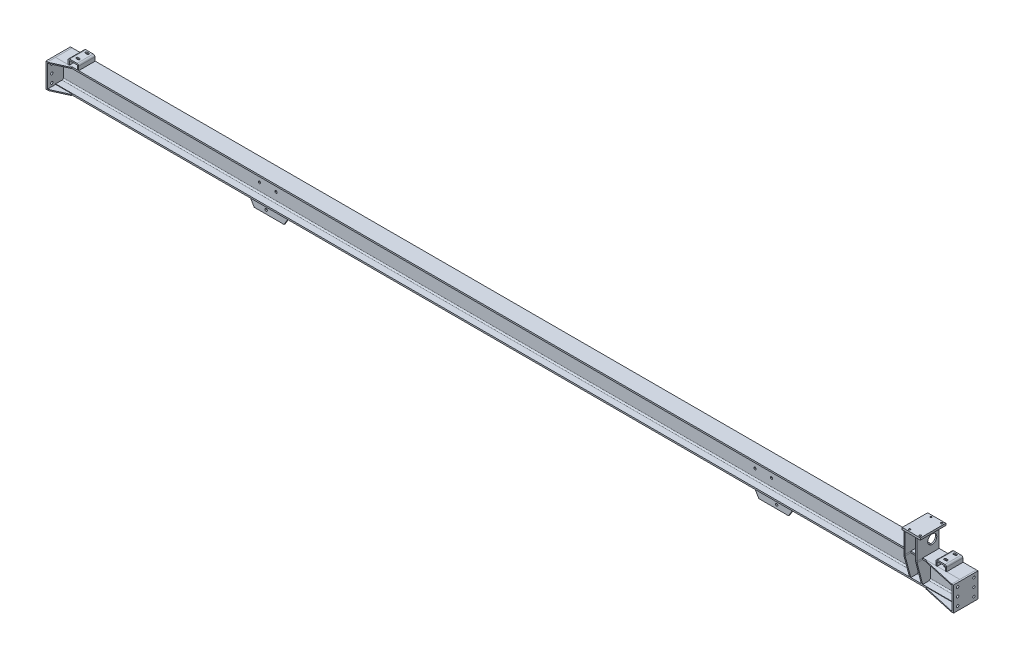
from build123d import *

# Parameters (mm, degrees)
H_HM150_100_3_DEPTH      = 5475
SKETCH_18_W              = 148
SKETCH_18_H              = 148
EXTRUDE_1_DEPTH          = 10
SKETCH_19_W              = 148
SKETCH_19_H              = 148
EXTRUDE_2_DEPTH          = 10
EXTRUDE_3_DEPTH          = 6
EXTRUDE_4_DEPTH          = 6
EXTRUDE_5_DEPTH          = 6
EXTRUDE_6_DEPTH          = 6
SKETCH_24_R              = 7
CUT_EXTRUDE_1_DEPTH      = 10
SKETCH_25_R              = 7
CUT_EXTRUDE_2_DEPTH      = 10
SKETCH_26_R              = 7
CUT_EXTRUDE_3_DEPTH      = 7593.985158926
CUT_EXTRUDE_3_DEPTH_BACK = 6
SKETCH_27_W              = 110
SKETCH_27_H              = 154
SKETCH_27_R              = 5.5
EXTRUDE_7_DEPTH          = 12
SKETCH_29_W              = 8
SKETCH_29_H              = 134
EXTRUDE_8_DEPTH          = 130
EXTRUDE_8_2_DEPTH        = 130
SKETCH_30_W              = 8
SKETCH_30_H              = 34
EXTRUDE_9_DEPTH          = 9
EXTRUDE_9_2_DEPTH        = 9
EXTRUDE_10_DEPTH         = 8
EXTRUDE_11_DEPTH         = 8
CUT_EXTRUDE_START        = -80
SKETCH_33_R              = 27.5
CUT_EXTRUDE_4_DEPTH      = 80
EXTRUDE_12_DEPTH         = 65
EXTRUDE_13_DEPTH         = 65
SKETCH_38_W              = 300
SKETCH_38_H              = 8
EXTRUDE_14_DEPTH         = 120
CHAMFER_1_SIZE           = 100
CHAMFER_1_SIZE2          = 60
CHAMFER_2_SIZE           = 100
CHAMFER_2_SIZE2          = 60
SKETCH_39_R              = 7
CUT_EXTRUDE_7_DEPTH      = 8
SKETCH_40_W              = 65
SKETCH_40_H              = 32
CUT_EXTRUDE_8_DEPTH      = 33.5
SKETCH_41_W              = 65
SKETCH_41_H              = 32
CUT_EXTRUDE_9_DEPTH      = 33.5
SKETCH_42_W              = 300
SKETCH_42_H              = 8
EXTRUDE_15_DEPTH         = 120
CHAMFER_3_SIZE           = 100
CHAMFER_3_SIZE2          = 60
CHAMFER_4_SIZE           = 100
CHAMFER_4_SIZE2          = 60
SKETCH_43_R              = 7
CUT_EXTRUDE_10_DEPTH     = 8
CUT_EXTRUDE_11_DEPTH     = 8
SKETCH_45_R              = 9
CUT_EXTRUDE_12_DEPTH     = 9
CUT_EXTRUDE_13_DEPTH     = 8
EXTRUDE_18_DEPTH         = 6


with BuildPart() as part:
    # 草图1 → H型钢 HM150×100(3) (new body)
    with BuildSketch(Plane(origin=(4200.913235594, -6243.549552316, 50), x_dir=(0, 0, 1), z_dir=(-1, 0, 0))):
        with BuildLine():
            Line((-50, -74), (50, -74))
            Line((50, -74), (50, -65))
            Line((50, -65), (11, -65))
            ThreePointArc((11, -65), (5.343145751, -62.656854249), (3, -57))
            Line((3, -57), (3, 57))
            ThreePointArc((3, 57), (5.343145751, 62.656854249), (11, 65))
            Line((11, 65), (50, 65))
            Line((50, 65), (50, 74))
            Line((50, 74), (-50, 74))
            Line((-50, 74), (-50, 65))
            Line((-50, 65), (-11, 65))
            ThreePointArc((-11, 65), (-5.343145751, 62.656854249), (-3, 57))
            Line((-3, 57), (-3, -57))
            ThreePointArc((-3, -57), (-5.343145751, -62.656854249), (-11, -65))
            Line((-11, -65), (-50, -65))
            Line((-50, -65), (-50, -74))
        make_face()
    extrude(amount=H_HM150_100_3_DEPTH)

    # 草图26 → 切除-拉伸3 (cut, two sides)
    with BuildSketch(Plane(origin=(0, 0, 47), x_dir=(-1, 0, 0), z_dir=(0, 0, -1))) as cut_extrude_3_sk:
        with Locations(Location((-3013.413235594, -6204.549552316, 0), (0, 0, 270))):
            Circle(SKETCH_26_R)
        with Locations(Location((-2913.413235594, -6204.549552316, 0), (0, 0, 270))):
            Circle(SKETCH_26_R)
        with Locations(Location((-13.413235594, -6204.549552316, 0), (0, 0, 270))):
            Circle(SKETCH_26_R)
        with Locations(Location((86.586764406, -6204.549552316, 0), (0, 0, 270))):
            Circle(SKETCH_26_R)
        with Locations(Location((-3013.413235594, -6254.549552316, 0), (0, 0, 270))):
            Circle(SKETCH_26_R)
        with Locations(Location((-2913.413235594, -6254.549552316, 0), (0, 0, 270))):
            Circle(SKETCH_26_R)
        with Locations(Location((-13.413235594, -6254.549552316, 0), (0, 0, 270))):
            Circle(SKETCH_26_R)
        with Locations(Location((86.586764406, -6254.549552316, 0), (0, 0, 270))):
            Circle(SKETCH_26_R)
    extrude(amount=CUT_EXTRUDE_3_DEPTH, mode=Mode.SUBTRACT)
    extrude(cut_extrude_3_sk.sketch, amount=-CUT_EXTRUDE_3_DEPTH_BACK, mode=Mode.SUBTRACT)

    # 草图45 → 切除-拉伸12 (cut)
    with BuildSketch(Plane(origin=(0, -6169.549552316, 0), x_dir=(1, 0, 0), z_dir=(0, 1, 0))):
        with Locations(Location((4088.413235594, -16, 0), (0, 0, 180))):
            Circle(SKETCH_45_R)
        with Locations(Location((4088.413235594, -72, 0), (0, 0, 180))):
            Circle(SKETCH_45_R)
    extrude(amount=-CUT_EXTRUDE_12_DEPTH, mode=Mode.SUBTRACT)


with BuildPart() as body_2:
    # 草图18 → 凸台-拉伸1 (new body)
    with BuildSketch(Plane(origin=(4200.913235594, 0, 0), x_dir=(0, 0, -1), z_dir=(1, 0, 0))):
        with Locations((-74, -6243.549552316)):
            Rectangle(SKETCH_18_W, SKETCH_18_H)
    extrude(amount=EXTRUDE_1_DEPTH)

    # 草图25 → 切除-拉伸2 (cut)
    with BuildSketch(Plane(origin=(4210.913235594, 0, 0), x_dir=(0, 0, -1), z_dir=(1, 0, 0))):
        with Locations(Location((-123, -6192.549552316, 0), (0, 0, 180))):
            Circle(SKETCH_25_R)
        with Locations(Location((-25, -6192.549552316, 0), (0, 0, 180))):
            Circle(SKETCH_25_R)
        with Locations(Location((-123, -6242.549552316, 0), (0, 0, 180))):
            Circle(SKETCH_25_R)
        with Locations(Location((-25, -6242.549552316, 0), (0, 0, 180))):
            Circle(SKETCH_25_R)
        with Locations(Location((-123, -6292.549552316, 0), (0, 0, 180))):
            Circle(SKETCH_25_R)
        with Locations(Location((-25, -6292.549552316, 0), (0, 0, 180))):
            Circle(SKETCH_25_R)
    extrude(amount=-CUT_EXTRUDE_2_DEPTH, mode=Mode.SUBTRACT)


with BuildPart() as body_3:
    # 草图19 → 凸台-拉伸2 (new body)
    with BuildSketch(Plane.ZY.offset(1274.086764406)):
        with Locations((74, -6243.549552316)):
            Rectangle(SKETCH_19_W, SKETCH_19_H)
    extrude(amount=EXTRUDE_2_DEPTH)

    # 草图24 → 切除-拉伸1 (cut)
    with BuildSketch(Plane.ZY.offset(1284.086764406)):
        with Locations((25, -6192.549552316)):
            Circle(SKETCH_24_R)
        with Locations((123, -6192.549552316)):
            Circle(SKETCH_24_R)
        with Locations((25, -6242.549552316)):
            Circle(SKETCH_24_R)
        with Locations((123, -6242.549552316)):
            Circle(SKETCH_24_R)
        with Locations((25, -6292.549552316)):
            Circle(SKETCH_24_R)
        with Locations((123, -6292.549552316)):
            Circle(SKETCH_24_R)
    extrude(amount=-CUT_EXTRUDE_1_DEPTH, mode=Mode.SUBTRACT)


with BuildPart() as body_4:
    # 草图20 → 凸台-拉伸3 (new body)
    with BuildSketch(Plane(origin=(0, -6169.549552316, 0), x_dir=(1, 0, 0), z_dir=(0, 1, 0))):
        Polygon((-1274.086764406, -100), (-1274.086764406, -148), (-1269.086764406, -148), (-1174.086764406, -105), (-1174.086764406, -100), align=None)
    extrude(amount=-EXTRUDE_3_DEPTH)


with BuildPart() as body_5:
    # 草图21 → 凸台-拉伸4 (new body)
    with BuildSketch(Plane.XZ.offset(6317.549552316)):
        Polygon((-1269.086764406, 148), (-1274.086764406, 148), (-1274.086764406, 100), (-1174.086764406, 100), (-1174.086764406, 105), align=None)
    extrude(amount=-EXTRUDE_4_DEPTH)


with BuildPart() as body_6:
    # 草图22 → 凸台-拉伸5 (new body)
    with BuildSketch(Plane(origin=(0, -6169.549552316, 0), x_dir=(1, 0, 0), z_dir=(0, 1, 0))):
        Polygon((4200.913235594, -100), (4200.913235594, -148), (4195.913235594, -148), (4000.913235594, -105), (4000.913235594, -100), align=None)
    extrude(amount=-EXTRUDE_5_DEPTH)


with BuildPart() as body_7:
    # 草图23 → 凸台-拉伸6 (new body)
    with BuildSketch(Plane.XZ.offset(6317.549552316)):
        Polygon((4200.913235594, 148), (4195.913235594, 148), (4000.913235594, 105), (4000.913235594, 100), (4200.913235594, 100), align=None)
    extrude(amount=-EXTRUDE_6_DEPTH)


with BuildPart() as body_8:
    # 草图27 → 凸台-拉伸7 (new body)
    with BuildSketch(Plane(origin=(0, -6039.549552316, 0), x_dir=(1, 0, 0), z_dir=(0, 1, 0))):
        with Locations((3950.913235594, -67)):
            Rectangle(SKETCH_27_W, SKETCH_27_H)
        with Locations(Location((3993.413235594, -132, 0), (0, 0, 180))):
            Circle(SKETCH_27_R, mode=Mode.SUBTRACT)
        with Locations(Location((3928.413235594, -132, 0), (0, 0, 180))):
            Circle(SKETCH_27_R, mode=Mode.SUBTRACT)
        with Locations(Location((3993.413235594, -2, 0), (0, 0, 180))):
            Circle(SKETCH_27_R, mode=Mode.SUBTRACT)
        with Locations(Location((3928.413235594, -2, 0), (0, 0, 180))):
            Circle(SKETCH_27_R, mode=Mode.SUBTRACT)
    extrude(amount=EXTRUDE_7_DEPTH)


with BuildPart() as body_9:
    # 草图29 → 凸台-拉伸8 (new body)
    with BuildSketch(Plane.XZ.offset(6039.549552316)):
        with Locations((3899.913235594, 67)):
            Rectangle(SKETCH_29_W, SKETCH_29_H)
    extrude(amount=EXTRUDE_8_DEPTH)


with BuildPart() as body_10:
    # 草图29 → Extrude 8 2 (new body)
    with BuildSketch(Plane.XZ.offset(6039.549552316)):
        with Locations((3971.913235594, 67)):
            Rectangle(SKETCH_29_W, SKETCH_29_H)
    extrude(amount=EXTRUDE_8_2_DEPTH)


with BuildPart() as body_11:
    # 草图30 → 凸台-拉伸9 (new body)
    with BuildSketch(Plane.XZ.offset(6169.549552316)):
        with Locations((3899.913235594, 117)):
            Rectangle(SKETCH_30_W, SKETCH_30_H)
    extrude(amount=EXTRUDE_9_DEPTH)


with BuildPart() as body_12:
    # 草图30 → Extrude 9 2 (new body)
    with BuildSketch(Plane.XZ.offset(6169.549552316)):
        with Locations((3971.913235594, 117)):
            Rectangle(SKETCH_30_W, SKETCH_30_H)
    extrude(amount=EXTRUDE_9_2_DEPTH)


with BuildPart() as body_13:
    # 草图31 → 凸台-拉伸10 (new body)
    with BuildSketch(Plane.ZY.offset(-3895.913235594)):
        Polygon((100, -6178.549552316), (134, -6178.549552316), (100, -6308.549552316), (61, -6308.549552316), (53, -6300.549552316), (53, -6186.549552316), (61, -6178.549552316), align=None)
    extrude(amount=-EXTRUDE_10_DEPTH)


with BuildPart() as body_14:
    # 草图32 → 凸台-拉伸11 (new body)
    with BuildSketch(Plane(origin=(3975.913235594, 0, 0), x_dir=(0, 0, -1), z_dir=(1, 0, 0))):
        Polygon((-61, -6178.549552316), (-134, -6178.549552316), (-100, -6308.549552316), (-61, -6308.549552316), (-53, -6300.549552316), (-53, -6186.549552316), align=None)
    extrude(amount=-EXTRUDE_11_DEPTH)


with BuildPart() as cut_extrude_4_tool:
    # 草图33 → 切除-拉伸4 (new body)
    with BuildSketch(Plane.ZY.offset(-3895.913235594).offset(CUT_EXTRUDE_START)):
        with Locations((42, -6099.549552316)):
            Circle(SKETCH_33_R)
    extrude(amount=CUT_EXTRUDE_4_DEPTH)


with BuildPart() as body_9_1:
    add(body_9.part)

    # 切除-拉伸4: cut by cut_extrude_4_tool
    add(cut_extrude_4_tool.part, mode=Mode.SUBTRACT)


with BuildPart() as body_10_1:
    add(body_10.part)

    # 切除-拉伸4: cut by cut_extrude_4_tool
    add(cut_extrude_4_tool.part, mode=Mode.SUBTRACT)


with BuildPart() as body_15:
    # 草图34 → 凸台-拉伸12 (new, symmetric)
    with BuildSketch(Plane(origin=(0, 0, 67), x_dir=(-1, 0, 0), z_dir=(0, 0, -1))):
        with BuildLine():
            Line((-4120.913235594, -6169.549552316), (-4112.913235594, -6169.549552316))
            Line((-4112.913235594, -6169.549552316), (-4112.913235594, -6146.049552316))
            ThreePointArc((-4112.913235594, -6146.049552316), (-4112.327449156, -6144.635338754), (-4110.913235594, -6144.049552316))
            Line((-4110.913235594, -6144.049552316), (-4065.913235594, -6144.049552316))
            ThreePointArc((-4065.913235594, -6144.049552316), (-4064.499022032, -6144.635338754), (-4063.913235594, -6146.049552316))
            Line((-4063.913235594, -6146.049552316), (-4063.913235594, -6169.549552316))
            Line((-4063.913235594, -6169.549552316), (-4055.913235594, -6169.549552316))
            Line((-4055.913235594, -6169.549552316), (-4055.913235594, -6146.049552316))
            ThreePointArc((-4055.913235594, -6146.049552316), (-4058.842167782, -6138.978484504), (-4065.913235594, -6136.049552316))
            Line((-4065.913235594, -6136.049552316), (-4110.913235594, -6136.049552316))
            ThreePointArc((-4110.913235594, -6136.049552316), (-4117.984303406, -6138.978484504), (-4120.913235594, -6146.049552316))
            Line((-4120.913235594, -6146.049552316), (-4120.913235594, -6169.549552316))
        make_face()
    extrude(amount=EXTRUDE_12_DEPTH, both=True)

    # 草图40 → 切除-拉伸8 (cut)
    with BuildSketch(Plane(origin=(0, -6169.549552316, 0), x_dir=(1, 0, 0), z_dir=(0, 1, 0))):
        with Locations((4088.413235594, -116)):
            Rectangle(SKETCH_40_W, SKETCH_40_H)
    extrude(amount=CUT_EXTRUDE_8_DEPTH, mode=Mode.SUBTRACT)

    # 草图44 → 切除-拉伸11 (cut)
    with BuildSketch(Plane(origin=(0, -6136.049552316, 0), x_dir=(1, 0, 0), z_dir=(0, 1, 0))):
        with BuildLine():
            Line((4083.413235594, -10), (4093.413235594, -10))
            ThreePointArc((4093.413235594, -10), (4099.413235594, -16), (4093.413235594, -22))
            Line((4093.413235594, -22), (4083.413235594, -22))
            ThreePointArc((4083.413235594, -22), (4077.413235594, -16), (4083.413235594, -10))
        make_face()
        with BuildLine():
            Line((4083.413235594, -66), (4093.413235594, -66))
            ThreePointArc((4093.413235594, -66), (4099.413235594, -72), (4093.413235594, -78))
            Line((4093.413235594, -78), (4083.413235594, -78))
            ThreePointArc((4083.413235594, -78), (4077.413235594, -72), (4083.413235594, -66))
        make_face()
    extrude(amount=-CUT_EXTRUDE_11_DEPTH, mode=Mode.SUBTRACT)


with BuildPart() as body_16:
    # 草图36 → 凸台-拉伸13 (new, symmetric)
    with BuildSketch(Plane(origin=(0, 0, 67), x_dir=(-1, 0, 0), z_dir=(0, 0, -1))):
        with BuildLine():
            Line((1134.086764406, -6169.549552316), (1142.086764406, -6169.549552316))
            Line((1142.086764406, -6169.549552316), (1142.086764406, -6146.049552316))
            ThreePointArc((1142.086764406, -6146.049552316), (1142.672550844, -6144.635338754), (1144.086764406, -6144.049552316))
            Line((1144.086764406, -6144.049552316), (1189.086764406, -6144.049552316))
            ThreePointArc((1189.086764406, -6144.049552316), (1190.500977968, -6144.635338754), (1191.086764406, -6146.049552316))
            Line((1191.086764406, -6146.049552316), (1191.086764406, -6169.549552316))
            Line((1191.086764406, -6169.549552316), (1199.086764406, -6169.549552316))
            Line((1199.086764406, -6169.549552316), (1199.086764406, -6146.049552316))
            ThreePointArc((1199.086764406, -6146.049552316), (1196.157832218, -6138.978484504), (1189.086764406, -6136.049552316))
            Line((1189.086764406, -6136.049552316), (1144.086764406, -6136.049552316))
            ThreePointArc((1144.086764406, -6136.049552316), (1137.015696594, -6138.978484504), (1134.086764406, -6146.049552316))
            Line((1134.086764406, -6146.049552316), (1134.086764406, -6169.549552316))
        make_face()
    extrude(amount=EXTRUDE_13_DEPTH, both=True)

    # 草图41 → 切除-拉伸9 (cut)
    with BuildSketch(Plane(origin=(0, -6169.549552316, 0), x_dir=(1, 0, 0), z_dir=(0, 1, 0))):
        with Locations((-1166.586764406, -116)):
            Rectangle(SKETCH_41_W, SKETCH_41_H)
    extrude(amount=CUT_EXTRUDE_9_DEPTH, mode=Mode.SUBTRACT)

    # 草图46 → 切除-拉伸13 (cut)
    with BuildSketch(Plane(origin=(0, -6136.049552316, 0), x_dir=(1, 0, 0), z_dir=(0, 1, 0))):
        with BuildLine():
            Line((-1161.586764406, -78), (-1171.586764406, -78))
            ThreePointArc((-1171.586764406, -78), (-1177.586764406, -72), (-1171.586764406, -66))
            Line((-1171.586764406, -66), (-1161.586764406, -66))
            ThreePointArc((-1161.586764406, -66), (-1155.586764406, -72), (-1161.586764406, -78))
        make_face()
        with BuildLine():
            Line((-1161.586764406, -10), (-1171.586764406, -10))
            ThreePointArc((-1171.586764406, -10), (-1177.586764406, -16), (-1171.586764406, -22))
            Line((-1171.586764406, -22), (-1161.586764406, -22))
            ThreePointArc((-1161.586764406, -22), (-1155.586764406, -16), (-1161.586764406, -10))
        make_face()
    extrude(amount=-CUT_EXTRUDE_13_DEPTH, mode=Mode.SUBTRACT)


with BuildPart() as body_17:
    # 草图38 → 凸台-拉伸14 (new body)
    with BuildSketch(Plane.XZ.offset(6317.549552316)):
        with Locations((2990.913235594, 13)):
            Rectangle(SKETCH_38_W, SKETCH_38_H)
    extrude(amount=EXTRUDE_14_DEPTH)

    # 倒角1
    chamfer_1_edges = [body_17.edges().sort_by_distance(p)[0] for p in [
        (2840.913235594, -6437.549552316, 13),
    ]]
    chamfer_1_side = [body_17.faces().sort_by_distance(p)[0] for p in [
        (2840.913235594, -6377.549552316, 13),
    ]]
    chamfer(chamfer_1_edges, length=CHAMFER_1_SIZE, length2=CHAMFER_1_SIZE2, reference=chamfer_1_side[0])

    # 倒角2
    chamfer_2_edges = [body_17.edges().sort_by_distance(p)[0] for p in [
        (3140.913235594, -6437.549552316, 13),
    ]]
    chamfer_2_side = [body_17.faces().sort_by_distance(p)[0] for p in [
        (3140.913235594, -6377.549552316, 13),
    ]]
    chamfer(chamfer_2_edges, length=CHAMFER_2_SIZE, length2=CHAMFER_2_SIZE2, reference=chamfer_2_side[0])

    # 草图39 → 切除-拉伸7 (cut)
    with BuildSketch(Plane.XY.offset(17)):
        with Locations((2962.913235594, -6350.049552316)):
            Circle(SKETCH_39_R)
        with Locations((3008.799350502, -6415.581715859)):
            Circle(SKETCH_39_R)
    extrude(amount=-CUT_EXTRUDE_7_DEPTH, mode=Mode.SUBTRACT)


with BuildPart() as body_18:
    # 草图42 → 凸台-拉伸15 (new body)
    with BuildSketch(Plane.XZ.offset(6317.549552316)):
        with Locations((-64.086764406, 13)):
            Rectangle(SKETCH_42_W, SKETCH_42_H)
    extrude(amount=EXTRUDE_15_DEPTH)

    # 倒角3
    chamfer_3_edges = [body_18.edges().sort_by_distance(p)[0] for p in [
        (85.913235594, -6437.549552316, 13),
    ]]
    chamfer_3_side = [body_18.faces().sort_by_distance(p)[0] for p in [
        (85.913235594, -6377.549552316, 13),
    ]]
    chamfer(chamfer_3_edges, length=CHAMFER_3_SIZE, length2=CHAMFER_3_SIZE2, reference=chamfer_3_side[0])

    # 倒角4
    chamfer_4_edges = [body_18.edges().sort_by_distance(p)[0] for p in [
        (-214.086764406, -6437.549552316, 13),
    ]]
    chamfer_4_side = [body_18.faces().sort_by_distance(p)[0] for p in [
        (-214.086764406, -6377.549552316, 13),
    ]]
    chamfer(chamfer_4_edges, length=CHAMFER_4_SIZE, length2=CHAMFER_4_SIZE2, reference=chamfer_4_side[0])

    # 草图43 → 切除-拉伸10 (cut)
    with BuildSketch(Plane.XY.offset(17)):
        with Locations((-36.086764406, -6350.049552316)):
            Circle(SKETCH_43_R)
        with Locations((-81.972879314, -6415.581715859)):
            Circle(SKETCH_43_R)
    extrude(amount=-CUT_EXTRUDE_10_DEPTH, mode=Mode.SUBTRACT)


with BuildPart() as body_19:
    # 草图49 → 凸台-拉伸18 (new body)
    with BuildSketch(Plane.ZY.offset(-2965.913235594)):
        Polygon((47, -6188.549552316), (47, -6298.549552316), (37, -6308.549552316), (2, -6308.549552316), (2, -6178.549552316), (37, -6178.549552316), align=None)
    extrude(amount=EXTRUDE_18_DEPTH)


solid = Compound([part.part, body_2.part, body_3.part, body_4.part, body_5.part, body_6.part, body_7.part, body_8.part, body_11.part, body_12.part, body_13.part, body_14.part, body_9_1.part, body_10_1.part, body_15.part, body_16.part, body_17.part, body_18.part, body_19.part])
